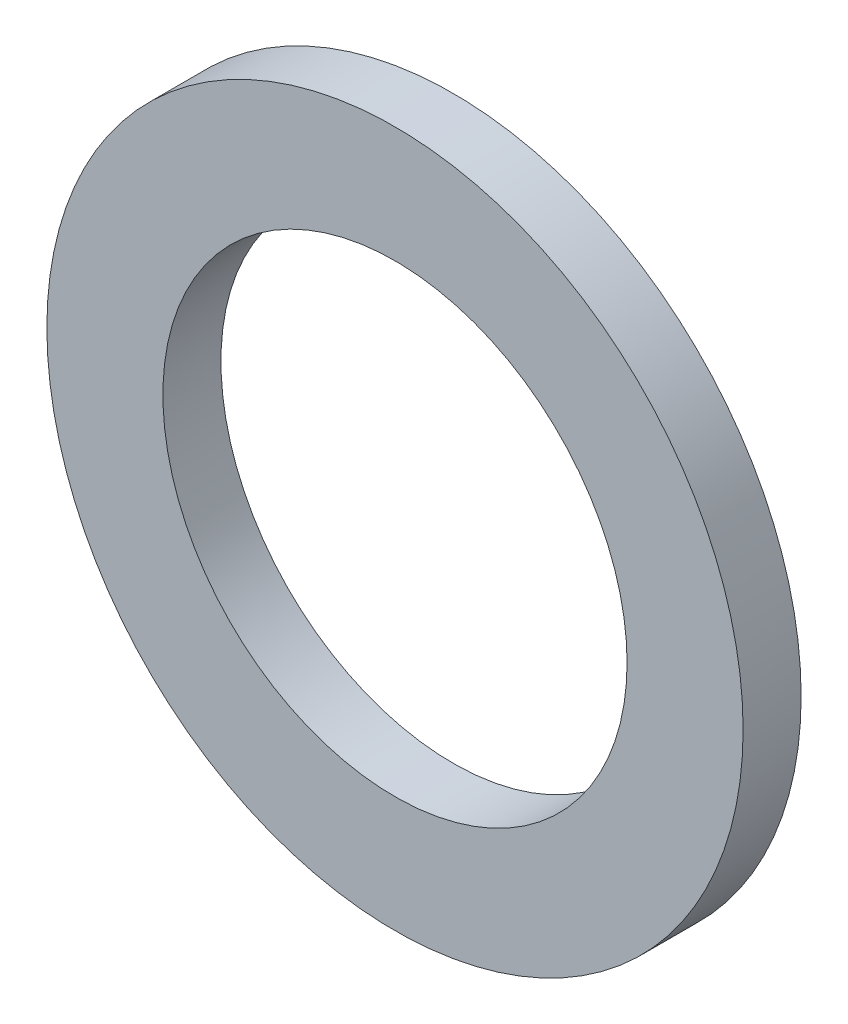
from build123d import *

# Parameters (mm, degrees)
CROQUIS1_R              = 19.05
CROQUIS1_R_2            = 12.7
SALIENTE_EXTRUIR1_DEPTH = 3.175


with BuildPart() as part:
    # Croquis1 → Saliente-Extruir1 (new body)
    with BuildSketch(Plane.XY):
        Circle(CROQUIS1_R)
        Circle(CROQUIS1_R_2, mode=Mode.SUBTRACT)
    extrude(amount=SALIENTE_EXTRUIR1_DEPTH)


solid = part.part
